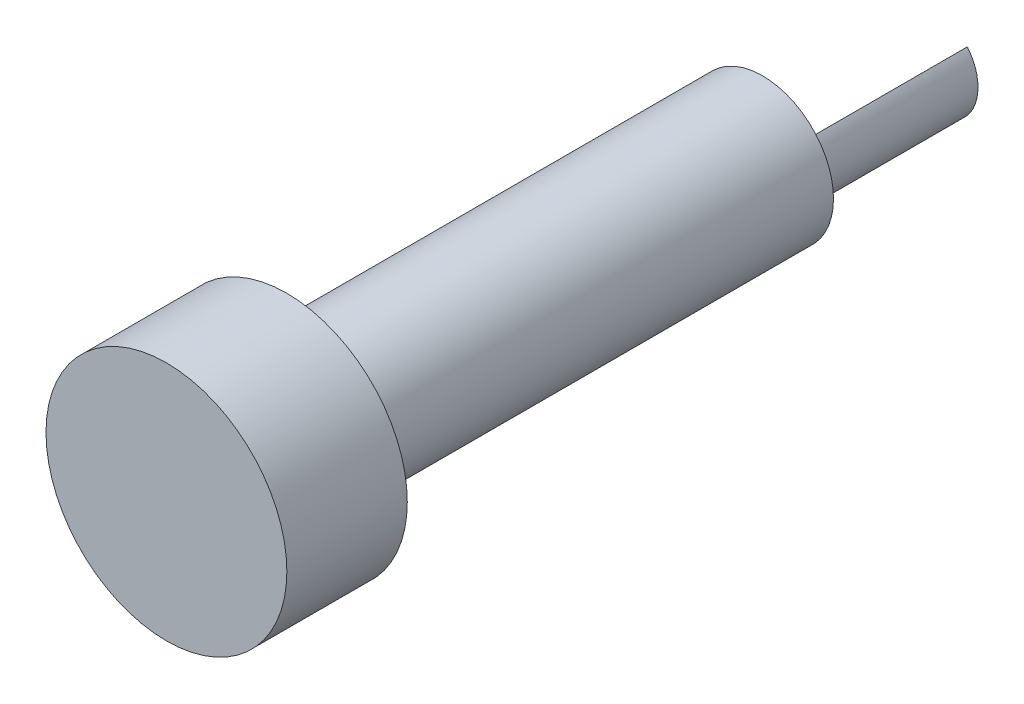
from build123d import *

# Parameters (mm, degrees)
BOSS_EXTRUDE1_DEPTH = 9.906
SKETCH6_R           = 1.975
BOSS_EXTRUDE2_DEPTH = 17.272
SKETCH7_R           = 2.99147738
BOSS_EXTRUDE3_DEPTH = 20.066
CUT_EXTRUDE1_DEPTH  = 20.066
SKETCH9_R           = 5.08
BOSS_EXTRUDE4_DEPTH = 5.08


with BuildPart() as part:
    # Sketch5 → Boss-Extrude1 (new body)
    with BuildSketch(Plane.XY):
        with BuildLine():
            Line((1.525, 0), (1.525, 1.25499004))
            ThreePointArc((1.525, 1.25499004), (1.975, 0), (1.525, -1.25499004))
            Line((1.525, -1.25499004), (1.525, 0))
        make_face()
    extrude(amount=BOSS_EXTRUDE1_DEPTH)

    # Sketch6 → Boss-Extrude2 (add)
    with BuildSketch(Plane.XY.offset(9.906)):
        Circle(SKETCH6_R)
    extrude(amount=BOSS_EXTRUDE2_DEPTH)

    # Sketch7 → Boss-Extrude3 (add)
    with BuildSketch(Plane.XY.offset(27.178)):
        Circle(SKETCH7_R)
    extrude(amount=-BOSS_EXTRUDE3_DEPTH)

    # Sketch8 → Cut-Extrude1 (cut)
    with BuildSketch(Plane.XY):
        with BuildLine():
            Line((1.525, 1.25499004), (1.525, 0))
            Line((1.525, 0), (1.525, -1.25499004))
            ThreePointArc((1.525, -1.25499004), (-1.975, 0), (1.525, 1.25499004))
        make_face()
    extrude(amount=CUT_EXTRUDE1_DEPTH, mode=Mode.SUBTRACT)

    # Sketch9 → Boss-Extrude4 (add)
    with BuildSketch(Plane.XY.offset(27.178)):
        Circle(SKETCH9_R)
    extrude(amount=BOSS_EXTRUDE4_DEPTH)


solid = part.part
